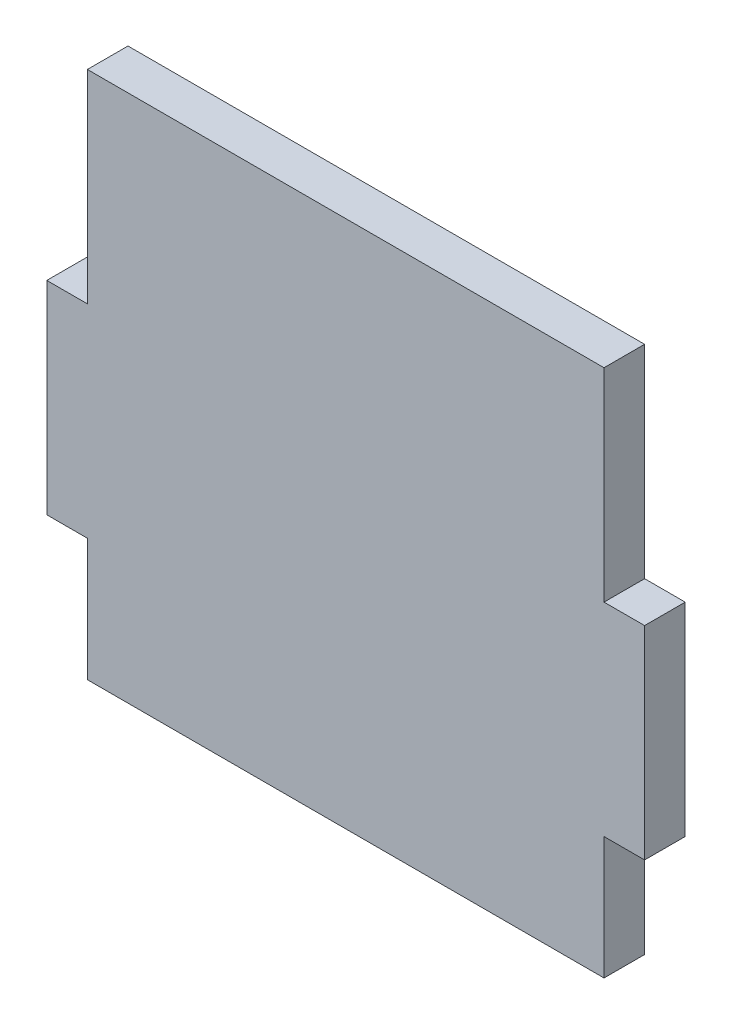
from build123d import *

# Parameters (mm, degrees)
SKETCH_1_W          = 4
SKETCH_1_H          = 20
EXTRUDE_1_DEPTH     = 4
SKETCH_2_W          = 70.761600996
SKETCH_2_H          = 28.517073099
CUT_EXTRUDE_1_DEPTH = 4
SKETCH_3_W          = 69.96653911
SKETCH_3_H          = 17
CUT_EXTRUDE_2_DEPTH = 10


with BuildPart() as part:
    # Эскиз1 → Бобышка-Вытянуть1 (new body)
    with BuildSketch(Plane.XY):
        with Locations((-52.9, -10)):
            Rectangle(SKETCH_1_W, SKETCH_1_H)
        with Locations((-52.9, -50)):
            Rectangle(SKETCH_1_W, SKETCH_1_H)
        Polygon((0, -20), (0, 0), (-50.9, 0), (-50.9, -20), (-50.9, -40), (-50.9, -60), (-50.9, -80), (-50.9, -89.071572875), (0, -89.071572875), (0, -60), (0, -40), align=None)
        with Locations((2, -10)):
            Rectangle(SKETCH_1_W, SKETCH_1_H)
        with Locations((2, -50)):
            Rectangle(SKETCH_1_W, SKETCH_1_H)
    extrude(amount=EXTRUDE_1_DEPTH)

    # Эскиз2 → Вырез-Вытянуть1 (cut)
    with BuildSketch(Plane(origin=(0, 0, 0), x_dir=(-1, 0, 0), z_dir=(0, 0, -1))):
        with Locations((19.519199502, -5.74146345)):
            Rectangle(SKETCH_2_W, SKETCH_2_H)
    extrude(amount=-CUT_EXTRUDE_1_DEPTH, mode=Mode.SUBTRACT)

    # Эскиз3 → Вырез-Вытянуть2 (cut)
    with BuildSketch(Plane(origin=(0, 0, 0), x_dir=(-1, 0, 0), z_dir=(0, 0, -1))):
        with Locations((15.916730445, -80.571572875)):
            Rectangle(SKETCH_3_W, SKETCH_3_H)
    extrude(amount=-CUT_EXTRUDE_2_DEPTH, mode=Mode.SUBTRACT)


solid = part.part
